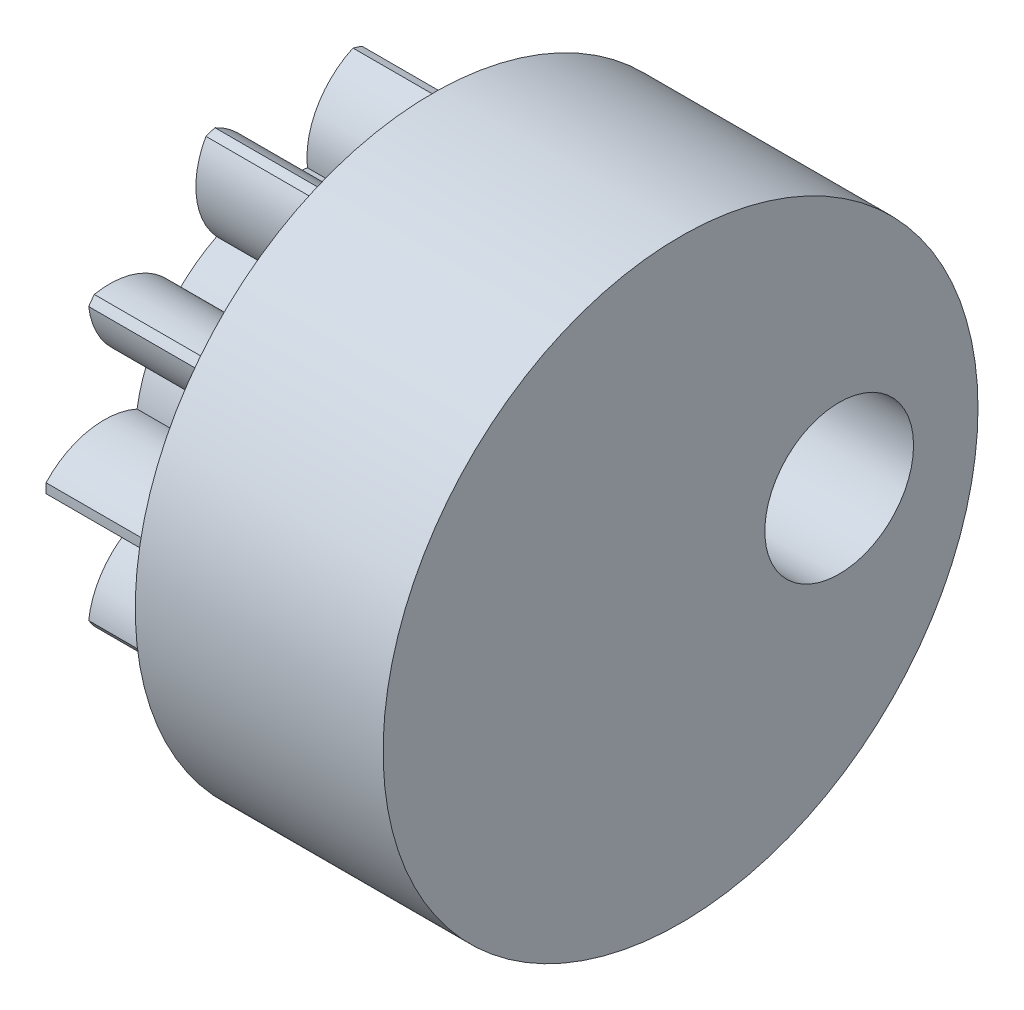
from build123d import *

# Parameters (mm, degrees)
BASPROSKE_W         = 8
BASPROSKE_H         = 4.8
TOOTHCUT_DEPTH      = 11.491901639
TEETHCUTS_COUNT     = 10
BORSKE_R            = 0.4
BORE_DEPTH          = 18.0000508
SKETCH1_R           = 6
BOSS_EXTRUDE1_DEPTH = 5
CUT_EXTRUDE1_DEPTH  = 5
SKETCH4_R           = 1.5
CUT_EXTRUDE2_DEPTH  = 7
SKETCH8_R           = 1.5
CUT_EXTRUDE8_DEPTH  = 4


with BuildPart() as part:
    # BasProSke → Base-Revolve (revolve)
    with BuildSketch(Plane(origin=(0, 0, 0), x_dir=(1, 0, 0), z_dir=(0, 1, 0)), mode=Mode.PRIVATE) as base_revolve_sk:
        with Locations((4, 2.4)):
            Rectangle(BASPROSKE_W, BASPROSKE_H)
    revolve(base_revolve_sk.sketch.rotate(Axis((-10, 0, 0), (1, 0, 0)), 180), axis=Axis((-10, 0, 0), (1, 0, 0)))

    # TooCutSke → ToothCut (cut, through all)
    with BuildSketch(Plane(origin=(0, 0, 0), x_dir=(0, 0, -1), z_dir=(1, 0, 0))):
        with BuildLine():
            ThreePointArc((0.473726058, 2.961348446), (0, 2.999), (-0.473726058, 2.961348446))
            ThreePointArc((-0.473726058, 2.961348446), (-0.678470427, 3.942691912), (-1.42693485, 4.6095924))
            ThreePointArc((-1.42693485, 4.6095924), (0, 4.8254), (1.42693485, 4.6095924))
            ThreePointArc((1.42693485, 4.6095924), (0.678470427, 3.942691912), (0.473726058, 2.961348446))
        make_face()
    toothcut = extrude(amount=TOOTHCUT_DEPTH, mode=Mode.SUBTRACT)

    # TeethCuts: ToothCut ×10 about axis
    teethcuts_axis = Axis((0, 0, 0), (1, 0, 0))
    for i in range(1, TEETHCUTS_COUNT):
        add(toothcut.rotate(teethcuts_axis, i * 360 / TEETHCUTS_COUNT), mode=Mode.SUBTRACT)

    # BorSke → Bore (cut, symmetric)
    with BuildSketch(Plane(origin=(0, 0, 0), x_dir=(0, 0, -1), z_dir=(1, 0, 0))):
        with Locations(Location((0, 0, 0), (0, 0, 180))):
            Circle(BORSKE_R)
    extrude(amount=BORE_DEPTH, both=True, mode=Mode.SUBTRACT)

    # Sketch1 → Boss-Extrude1 (add)
    with BuildSketch(Plane(origin=(8, 0, 0), x_dir=(0, 0, -1), z_dir=(1, 0, 0))):
        Circle(SKETCH1_R)
    extrude(amount=BOSS_EXTRUDE1_DEPTH)

    # Sketch2 → Cut-Extrude1 (cut)
    with BuildSketch(Plane.ZY):
        with BuildLine():
            ThreePointArc((-2.96279914, 0.464566741), (-3.940487364, 0.57700657), (-4.799040651, 0.09596267))
            ThreePointArc((-4.799040651, 0.09596267), (-4.8, 0), (-4.799040651, -0.09596267))
            ThreePointArc((-4.799040651, -0.09596267), (-3.940487364, -0.57700657), (-2.96279914, -0.464566741))
            ThreePointArc((-2.96279914, -0.464566741), (-2.852218492, -0.926741966), (-2.670020334, -1.365647251))
            ThreePointArc((-2.670020334, -1.365647251), (-3.527077196, -1.849352238), (-3.938910885, -2.743169889))
            ThreePointArc((-3.938910885, -2.743169889), (-3.883281573, -2.821369211), (-3.826100001, -2.898440751))
            ThreePointArc((-3.826100001, -2.898440751), (-2.848765291, -2.782968481), (-2.123889376, -2.117332029))
            ThreePointArc((-2.123889376, -2.117332029), (-1.762767972, -2.426241966), (-1.357384512, -2.67423041))
            ThreePointArc((-1.357384512, -2.67423041), (-1.76644342, -3.569321349), (-1.574251041, -4.534504787))
            ThreePointArc((-1.574251041, -4.534504787), (-1.483281573, -4.565071278), (-1.391719195, -4.593812979))
            ThreePointArc((-1.391719195, -4.593812979), (-0.668911703, -3.925931021), (-0.473726058, -2.961348446))
            ThreePointArc((-0.473726058, -2.961348446), (0, -2.999), (0.473726058, -2.961348446))
            ThreePointArc((0.473726058, -2.961348446), (0.668911703, -3.925931021), (1.391719195, -4.593812979))
            ThreePointArc((1.391719195, -4.593812979), (1.483281573, -4.565071278), (1.574251041, -4.534504787))
            ThreePointArc((1.574251041, -4.534504787), (1.76644342, -3.569321349), (1.357384512, -2.67423041))
            ThreePointArc((1.357384512, -2.67423041), (1.762767972, -2.426241966), (2.123889376, -2.117332029))
            ThreePointArc((2.123889376, -2.117332029), (2.848765291, -2.782968481), (3.826100001, -2.898440751))
            ThreePointArc((3.826100001, -2.898440751), (3.883281573, -2.821369211), (3.938910885, -2.743169889))
            ThreePointArc((3.938910885, -2.743169889), (3.527077196, -1.849352238), (2.670020334, -1.365647251))
            ThreePointArc((2.670020334, -1.365647251), (2.852218492, -0.926741966), (2.96279914, -0.464566741))
            ThreePointArc((2.96279914, -0.464566741), (3.940487364, -0.57700657), (4.799040651, -0.09596267))
            ThreePointArc((4.799040651, -0.09596267), (4.8, 0), (4.799040651, 0.09596267))
            ThreePointArc((4.799040651, 0.09596267), (3.940487364, 0.57700657), (2.96279914, 0.464566741))
            ThreePointArc((2.96279914, 0.464566741), (2.852218492, 0.926741966), (2.670020334, 1.365647251))
            ThreePointArc((2.670020334, 1.365647251), (3.527077196, 1.849352238), (3.938910885, 2.743169889))
            ThreePointArc((3.938910885, 2.743169889), (3.883281573, 2.821369211), (3.826100001, 2.898440751))
            ThreePointArc((3.826100001, 2.898440751), (2.848765291, 2.782968481), (2.123889376, 2.117332029))
            ThreePointArc((2.123889376, 2.117332029), (1.762767972, 2.426241966), (1.357384512, 2.67423041))
            ThreePointArc((1.357384512, 2.67423041), (1.76644342, 3.569321349), (1.574251041, 4.534504787))
            ThreePointArc((1.574251041, 4.534504787), (1.483281573, 4.565071278), (1.391719195, 4.593812979))
            ThreePointArc((1.391719195, 4.593812979), (0.668911703, 3.925931021), (0.473726058, 2.961348446))
            ThreePointArc((0.473726058, 2.961348446), (0, 2.999), (-0.473726058, 2.961348446))
            ThreePointArc((-0.473726058, 2.961348446), (-0.668911703, 3.925931021), (-1.391719195, 4.593812979))
            ThreePointArc((-1.391719195, 4.593812979), (-1.483281573, 4.565071278), (-1.574251041, 4.534504787))
            ThreePointArc((-1.574251041, 4.534504787), (-1.76644342, 3.569321349), (-1.357384512, 2.67423041))
            ThreePointArc((-1.357384512, 2.67423041), (-1.762767972, 2.426241966), (-2.123889376, 2.117332029))
            ThreePointArc((-2.123889376, 2.117332029), (-2.848765291, 2.782968481), (-3.826100001, 2.898440751))
            ThreePointArc((-3.826100001, 2.898440751), (-3.883281573, 2.821369211), (-3.938910885, 2.743169889))
            ThreePointArc((-3.938910885, 2.743169889), (-3.527077196, 1.849352238), (-2.670020334, 1.365647251))
            ThreePointArc((-2.670020334, 1.365647251), (-2.852218492, 0.926741966), (-2.96279914, 0.464566741))
        make_face()
    extrude(amount=-CUT_EXTRUDE1_DEPTH, mode=Mode.SUBTRACT)

    # Sketch4 → Cut-Extrude2 (cut)
    with BuildSketch(Plane.ZY.offset(-5)):
        Circle(SKETCH4_R)
    extrude(amount=-CUT_EXTRUDE2_DEPTH, mode=Mode.SUBTRACT)

    # Sketch8 → Cut-Extrude8 (cut)
    with BuildSketch(Plane(origin=(13, 0, 0), x_dir=(0, 0, -1), z_dir=(1, 0, 0))):
        with Locations((3.2, 0)):
            Circle(SKETCH8_R)
    extrude(amount=-CUT_EXTRUDE8_DEPTH, mode=Mode.SUBTRACT)


solid = part.part
